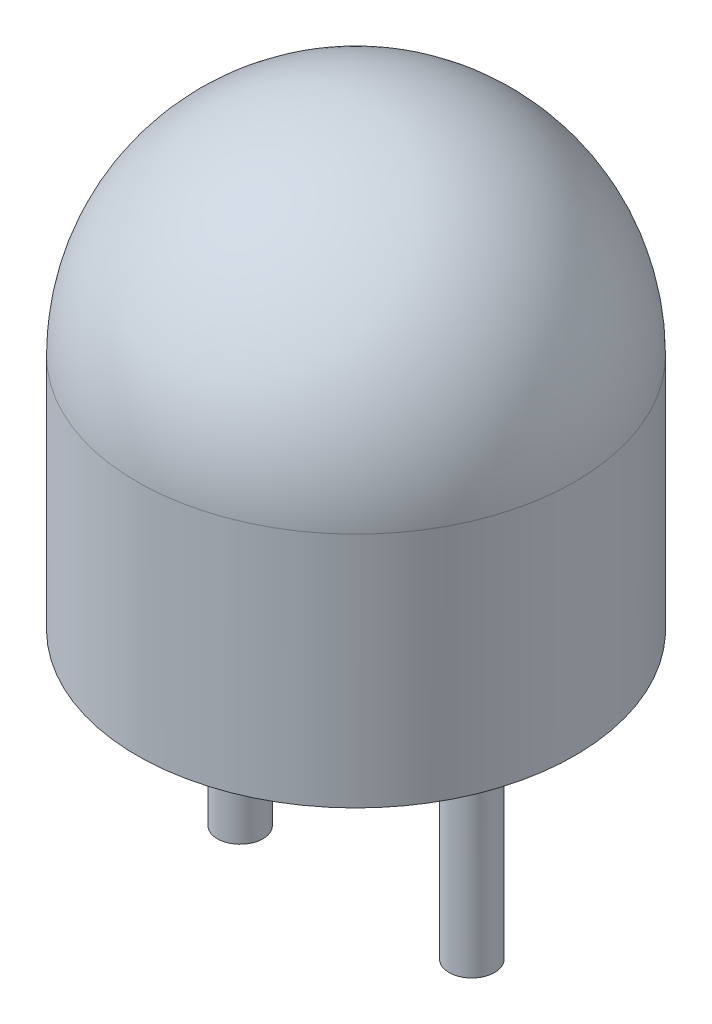
from build123d import *

# Parameters (mm, degrees)
ESQUISSE1_R          = 0.25
BOSS_EXTRU_1_DEPTH   = 2.5
BOSS_EXTRU_1_2_DEPTH = 2.5
BOSS_EXTRU_2_DEPTH   = 0.1


with BuildPart() as part:
    # Esquisse1 → Boss.-Extru.1 (new body)
    with BuildSketch(Plane(origin=(0, 0, 0), x_dir=(1, 0, 0), z_dir=(0, 1, 0))):
        with Locations(Location((1.27, 0, 0), (0, 0, 270))):  # turned: the seam where the file's is
            Circle(ESQUISSE1_R)
    extrude(amount=-BOSS_EXTRU_1_DEPTH)



with BuildPart() as body_2:
    # Esquisse1 → Boss.-Extru.1 2 (new body)
    with BuildSketch(Plane(origin=(0, 0, 0), x_dir=(1, 0, 0), z_dir=(0, 1, 0))):
        with Locations(Location((-1.27, 0, 0), (0, 0, 270))):  # turned: the seam where the file's is
            Circle(ESQUISSE1_R)
    extrude(amount=-BOSS_EXTRU_1_2_DEPTH)


with BuildPart() as part_1:
    add(part.part)

    add(body_2.part)  # Boss.-Extru.2 merges body 2
    # Esquisse2 → Boss.-Extru.2 (add, symmetric)
    with BuildSketch(Plane.XY):
        with BuildLine():
            Line((1.52, 0), (1.52, 3))
            Line((1.52, 3), (-1.02, 3))
            Line((-1.02, 3), (0, 1.3))
            ThreePointArc((0, 1.3), (0.43392777, 0.876884866), (1.02, 0.722485813))
            Line((1.02, 0.722485813), (1.02, 0))
            Line((1.02, 0), (1.52, 0))
        make_face()
        Polygon((-1.52, 0), (-1.52, 3), (-0.5, 1.3), (-1.02, 1.3), (-1.02, 0), align=None)
    extrude(amount=BOSS_EXTRU_2_DEPTH, both=True)

    # Esquisse4 → Révolution1 (revolve)
    with BuildSketch(Plane.XY):
        Polygon((0, 3), (0.5, 3), (0, 2.5), align=None)
    revolve(axis=Axis((0, 2.5, 0), (0, 1, 0)))


with BuildPart() as body_2_2:
    # Esquisse5 → Révolution2 (revolve)
    with BuildSketch(Plane.XY, mode=Mode.PRIVATE) as r_volution2_sk:
        with BuildLine():
            Line((0, 0), (0, 5))
            ThreePointArc((0, 5), (1.697056275, 4.297056275), (2.4, 2.6))
            Line((2.4, 2.6), (2.4, 0))
            Line((2.4, 0), (0, 0))
        make_face()
    revolve(r_volution2_sk.sketch.rotate(Axis((0, 0, 0), (0, 1, 0)), 90), axis=Axis((0, 0, 0), (0, 1, 0)))  # turned: the seam where the file's is


solid = Compound([part_1.part, body_2_2.part])
